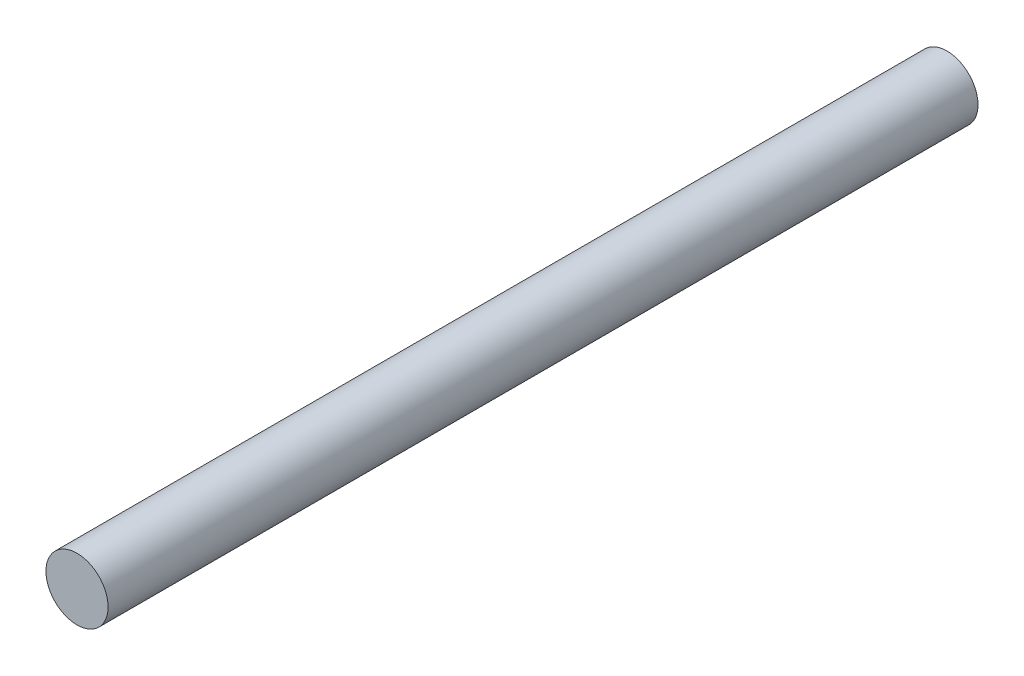
from build123d import *

# Parameters (mm, degrees)
SKETCH_1_R      = 2.5
EXTRUDE_1_DEPTH = 70


with BuildPart() as part:
    # ｽｹｯﾁ1 → ﾎﾞｽ - 押し出し1 (new body)
    with BuildSketch(Plane.XY):
        Circle(SKETCH_1_R)
    extrude(amount=EXTRUDE_1_DEPTH)


solid = part.part
